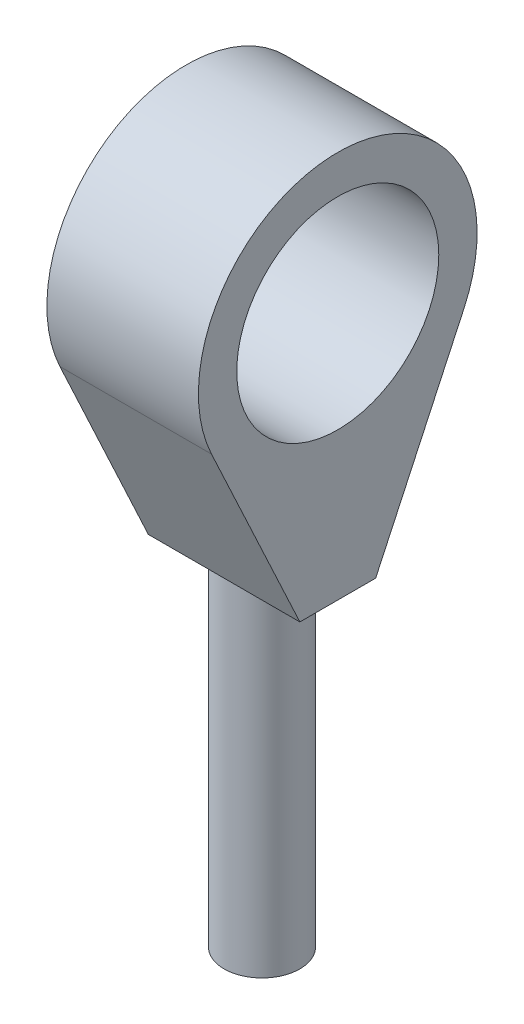
from build123d import *

# Parameters (mm, degrees)
SKETCH2_R                = 4.7625
BOSS_EXTRUDE1_DEPTH      = 42.545
BOSS_EXTRUDE2_DEPTH      = 9.525
BOSS_EXTRUDE2_DEPTH_BACK = 9.525
SKETCH3_R                = 12.7


with BuildPart() as part:
    # Sketch2 → Boss-Extrude1 (new body)
    with BuildSketch(Plane(origin=(0, 0, 0), x_dir=(1, 0, 0), z_dir=(0, 1, 0))):
        Circle(SKETCH2_R)
    extrude(amount=BOSS_EXTRUDE1_DEPTH)

    # Sketch3 → Boss-Extrude2 (add, two sides: drawn at the far end of the back side and taken through both)
    with BuildSketch(Plane(origin=(0, 0, 0), x_dir=(0, 0, -1), z_dir=(1, 0, 0)).offset(-BOSS_EXTRUDE2_DEPTH_BACK)):
        with BuildLine():
            Line((-4.7625, 42.545), (-15.875, 66.375833154))
            ThreePointArc((-15.875, 66.375833154), (0, 91.294591691), (15.875, 66.375833154))
            Line((15.875, 66.375833154), (4.7625, 42.545))
            Line((4.7625, 42.545), (-4.7625, 42.545))
        make_face()
        with Locations((0, 73.778467227)):
            Circle(SKETCH3_R, mode=Mode.SUBTRACT)
    extrude(amount=BOSS_EXTRUDE2_DEPTH + BOSS_EXTRUDE2_DEPTH_BACK)


solid = part.part
